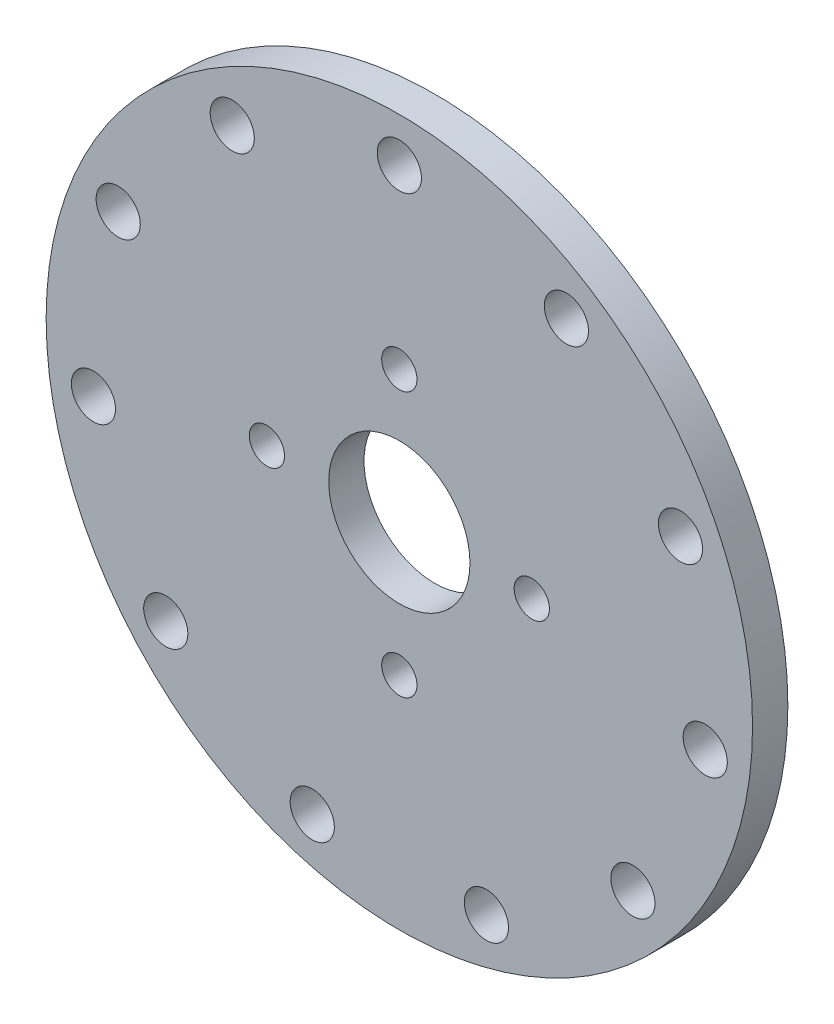
from build123d import *

# Parameters (mm, degrees)
SKETCH1_R           = 40
SKETCH1_R_2         = 8
BOSS_EXTRUDE1_DEPTH = 4
SKETCH2_R           = 2.5
CUT_EXTRUDE1_DEPTH  = 4
SKETCH3_R           = 2
CUT_EXTRUDE2_DEPTH  = 4


with BuildPart() as part:
    # Sketch1 → Boss-Extrude1 (new body)
    with BuildSketch(Plane.XY):
        Circle(SKETCH1_R)
        Circle(SKETCH1_R_2, mode=Mode.SUBTRACT)
    extrude(amount=BOSS_EXTRUDE1_DEPTH)

    # Sketch2 → Cut-Extrude1 (cut)
    with BuildSketch(Plane.XY.offset(4)):
        with Locations((0, 35)):
            Circle(SKETCH2_R)
        with Locations((18.922428611, 29.443873649)):
            Circle(SKETCH2_R)
        with Locations((31.837119837, 14.539525455)):
            Circle(SKETCH2_R)
        with Locations((34.643750466, -4.98101934)):
            Circle(SKETCH2_R)
        with Locations((26.451235102, -22.920125688)):
            Circle(SKETCH2_R)
        with Locations((9.860639489, -33.582254077)):
            Circle(SKETCH2_R)
        with Locations((-9.860639489, -33.582254077)):
            Circle(SKETCH2_R)
        with Locations((-26.451235102, -22.920125688)):
            Circle(SKETCH2_R)
        with Locations((-34.643750466, -4.98101934)):
            Circle(SKETCH2_R)
        with Locations((-31.837119837, 14.539525455)):
            Circle(SKETCH2_R)
        with Locations((-18.922428611, 29.443873649)):
            Circle(SKETCH2_R)
    extrude(amount=-CUT_EXTRUDE1_DEPTH, mode=Mode.SUBTRACT)

    # Sketch3 → Cut-Extrude2 (cut)
    with BuildSketch(Plane.XY.offset(4)):
        with Locations((0, 15)):
            Circle(SKETCH3_R)
        with Locations((15, 0)):
            Circle(SKETCH3_R)
        with Locations((0, -15)):
            Circle(SKETCH3_R)
        with Locations((-15, 0)):
            Circle(SKETCH3_R)
    extrude(amount=-CUT_EXTRUDE2_DEPTH, mode=Mode.SUBTRACT)


solid = part.part
